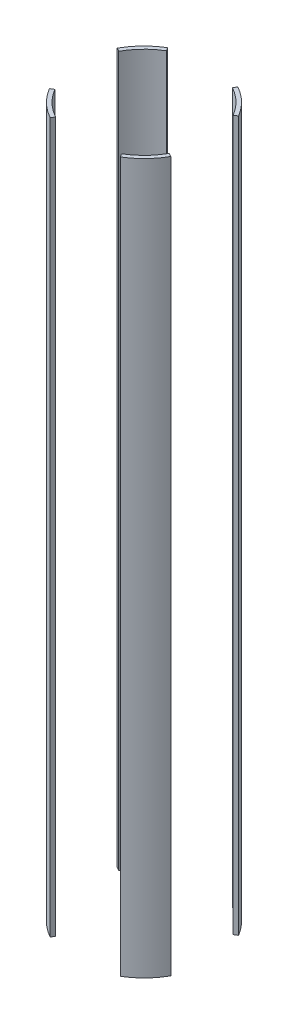
from build123d import *

# Parameters (mm, degrees)
SKETCH2_R               = 88.9
SKETCH2_R_2             = 83.82
BOSS_EXTRUDE1_DEPTH     = 457.2
CUT_EXTRUDE1_DEPTH      = 458.2
CUT_EXTRUDE1_DEPTH_BACK = 458.2


with BuildPart() as part:
    # Sketch2 → Boss-Extrude1 (new body, symmetric)
    with BuildSketch(Plane(origin=(0, 0, 0), x_dir=(1, 0, 0), z_dir=(0, 1, 0))):
        Circle(SKETCH2_R)
        Circle(SKETCH2_R_2, mode=Mode.SUBTRACT)
    extrude(amount=BOSS_EXTRUDE1_DEPTH, both=True)

    # Sketch3 → Cut-Extrude1 (cut, two sides)
    with BuildSketch(Plane(origin=(0, 0, 0), x_dir=(1, 0, 0), z_dir=(0, 1, 0))) as cut_extrude1_sk:
        Polygon((169.661755759, -94.300371224), (0, 0), (169.661755759, 101.677593364), align=None)
        Polygon((0, 0), (53.900027233, 96.974944394), (-58.116685864, 96.974944394), align=None)
        Polygon((-123.741299607, 68.777140945), (-123.741299607, -74.157652604), (0, 0), align=None)
        Polygon((-65.840936026, -118.45858783), (0, 0), (70.991745134, -118.45858783), align=None)
    extrude(amount=CUT_EXTRUDE1_DEPTH, mode=Mode.SUBTRACT)
    extrude(cut_extrude1_sk.sketch, amount=-CUT_EXTRUDE1_DEPTH_BACK, mode=Mode.SUBTRACT)


solid = part.part
